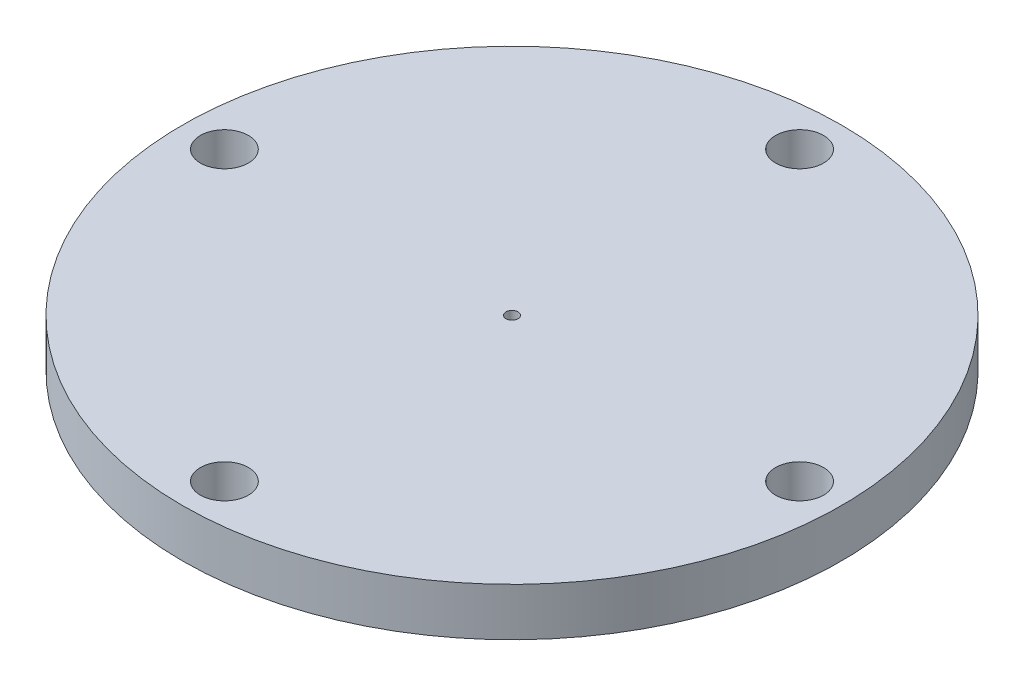
from build123d import *

# Parameters (mm, degrees)
SKETCH2_R           = 27.469
BOSS_EXTRUDE1_DEPTH = 4
SKETCH3_R           = 2
CUT_EXTRUDE1_DEPTH  = 5
SKETCH4_R           = 0.5
CUT_EXTRUDE2_DEPTH  = 6


with BuildPart() as part:
    # Sketch2 → Boss-Extrude1 (new body)
    with BuildSketch(Plane(origin=(0, 0, 0), x_dir=(1, 0, 0), z_dir=(0, 1, 0))):
        Circle(SKETCH2_R)
    extrude(amount=BOSS_EXTRUDE1_DEPTH)

    # Sketch3 → Cut-Extrude1 (cut, through all)
    with BuildSketch(Plane(origin=(0, 4, 0), x_dir=(1, 0, 0), z_dir=(0, 1, 0))):
        with Locations((-23.971, 0)):
            Circle(SKETCH3_R)
        with Locations((0, 23.971)):
            Circle(SKETCH3_R)
        with Locations((23.971, 0)):
            Circle(SKETCH3_R)
        with Locations((0, -23.971)):
            Circle(SKETCH3_R)
    extrude(amount=-CUT_EXTRUDE1_DEPTH, mode=Mode.SUBTRACT)

    # Sketch4 → Cut-Extrude2 (cut, through all)
    with BuildSketch(Plane(origin=(0, 5, 0), x_dir=(1, 0, 0), z_dir=(0, 1, 0))):
        Circle(SKETCH4_R)
    extrude(amount=-CUT_EXTRUDE2_DEPTH, mode=Mode.SUBTRACT)


solid = part.part
